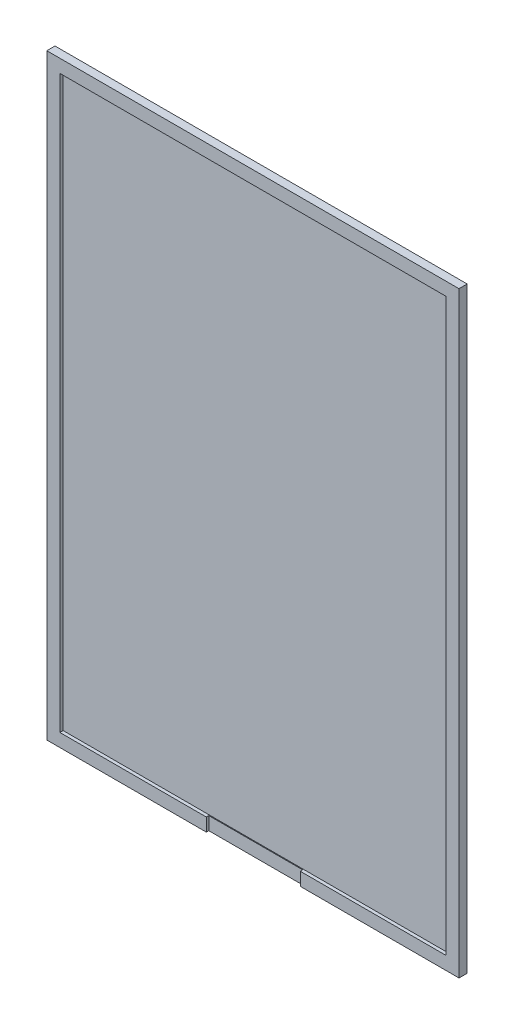
from build123d import *

# Parameters (mm, degrees)
CROQUIS1_W              = 50.4
CROQUIS1_H              = 73
SALIENTE_EXTRUIR1_DEPTH = 1
CROQUIS2_W              = 47.2
CROQUIS2_H              = 69.8
CORTAR_EXTRUIR1_DEPTH   = 0.4
CROQUIS3_W              = 11.5
CROQUIS3_H              = 1.6
CORTAR_EXTRUIR2_DEPTH   = 0.9


with BuildPart() as part:
    # Croquis1 → Saliente-Extruir1 (new body)
    with BuildSketch(Plane.XY):
        Rectangle(CROQUIS1_W, CROQUIS1_H)
    extrude(amount=SALIENTE_EXTRUIR1_DEPTH)

    # Croquis2 → Cortar-Extruir1 (cut)
    with BuildSketch(Plane.XY.offset(1)):
        Rectangle(CROQUIS2_W, CROQUIS2_H)
    extrude(amount=-CORTAR_EXTRUIR1_DEPTH, mode=Mode.SUBTRACT)

    # Croquis3 → Cortar-Extruir2 (cut)
    with BuildSketch(Plane.XY.offset(1.6)):
        with Locations((0.05, -35.7)):
            Rectangle(CROQUIS3_W, CROQUIS3_H)
    extrude(amount=-CORTAR_EXTRUIR2_DEPTH, mode=Mode.SUBTRACT)


solid = part.part
